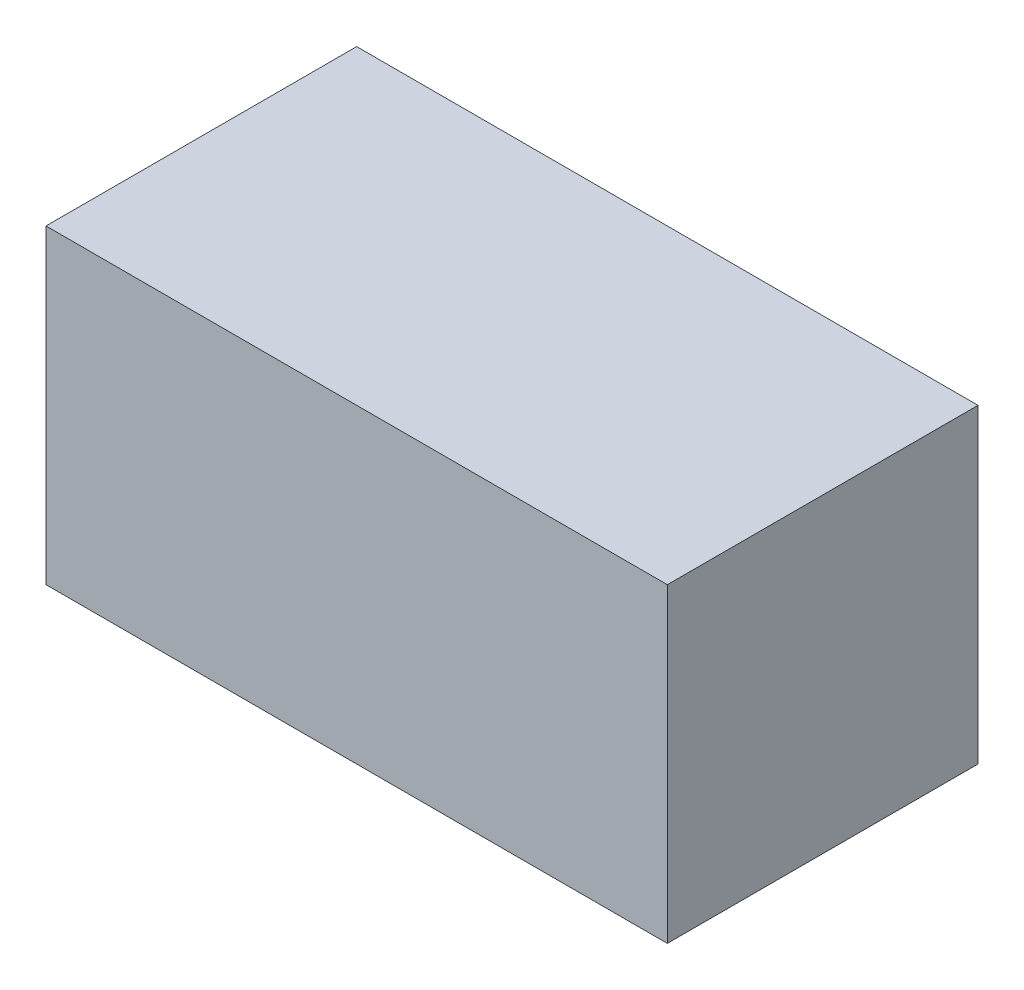
from build123d import *

# Parameters (mm, degrees)
SKETCH1_W           = 20
SKETCH1_H           = 10
BOSS_EXTRUDE1_DEPTH = 10


with BuildPart() as part:
    # Sketch1 → Boss-Extrude1 (new body)
    with BuildSketch(Plane(origin=(0, 0, 0), x_dir=(1, 0, 0), z_dir=(0, 1, 0))):
        Rectangle(SKETCH1_W, SKETCH1_H)
    extrude(amount=BOSS_EXTRUDE1_DEPTH)


solid = part.part
